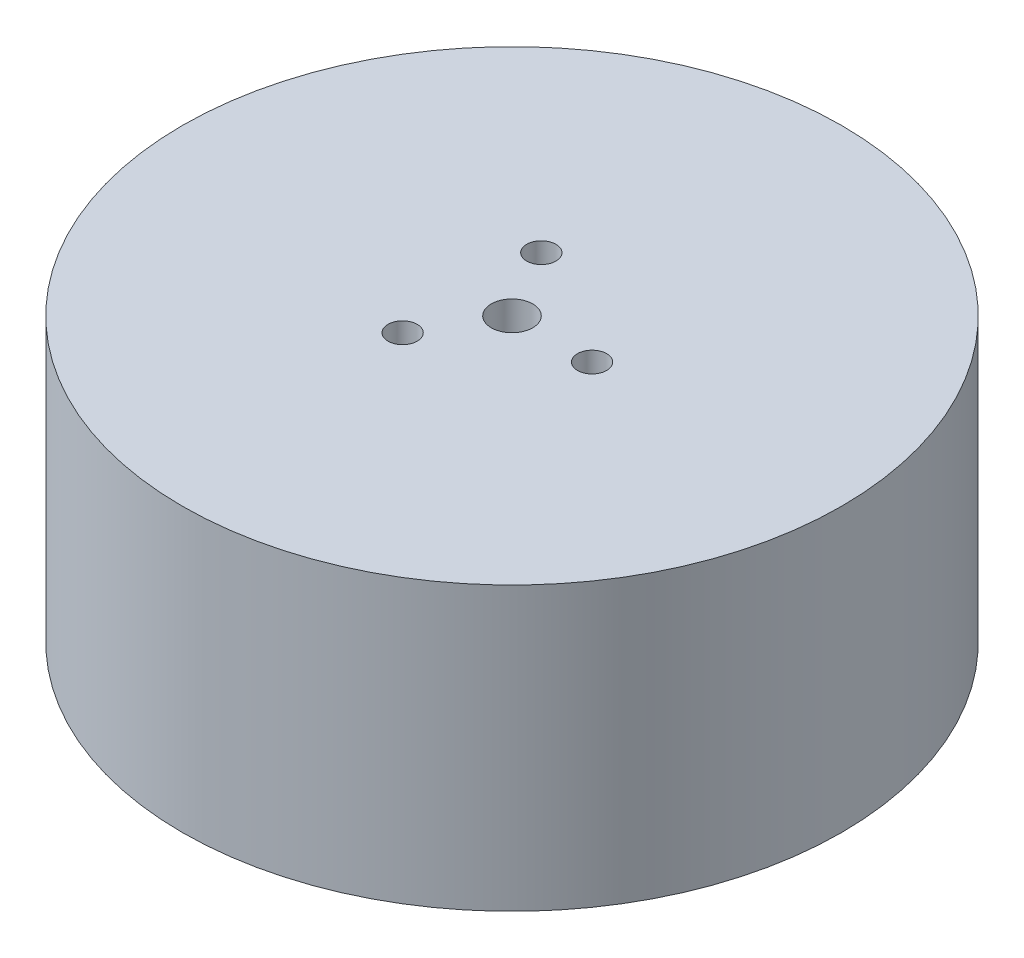
from build123d import *

# Parameters (mm, degrees)
SKETCH_1_R          = 35
EXTRUDE_1_DEPTH     = 30
SKETCH_2_R          = 23.2
CUT_EXTRUDE_1_DEPTH = 26
CUT_EXTRUDE_2_REACH = 32
SKETCH_3_R          = 2.2
SKETCH_3_R_2        = 1.55


with BuildPart() as part:
    # 草图1 → 凸台-拉伸1 (new body)
    with BuildSketch(Plane(origin=(0, 0, 0), x_dir=(1, 0, 0), z_dir=(0, 1, 0))):
        Circle(SKETCH_1_R)
    extrude(amount=EXTRUDE_1_DEPTH)

    # 草图2 → 切除-拉伸1 (cut)
    with BuildSketch(Plane.XZ):
        Circle(SKETCH_2_R)
    extrude(amount=-CUT_EXTRUDE_1_DEPTH, mode=Mode.SUBTRACT)

    # 草图3 → 切除-拉伸2 (cut, up to next)
    with BuildSketch(Plane(origin=(0, 30, 0), x_dir=(1, 0, 0), z_dir=(0, 1, 0)), mode=Mode.PRIVATE) as cut_extrude_2_sk1:
        Circle(SKETCH_3_R)
    cut_extrude_2_tool1 = extrude(cut_extrude_2_sk1.sketch, amount=-CUT_EXTRUDE_2_REACH, mode=Mode.PRIVATE) & part.part
    add(cut_extrude_2_tool1.solids().sort_by_distance((0, 30, 0))[0], mode=Mode.SUBTRACT)
    # 草图3 → 切除-拉伸2 (cut, up to next)
    with BuildSketch(Plane(origin=(0, 30, 0), x_dir=(1, 0, 0), z_dir=(0, 1, 0)), mode=Mode.PRIVATE) as cut_extrude_2_sk2:
        with Locations((8.5, 0)):
            Circle(SKETCH_3_R_2)
    cut_extrude_2_tool2 = extrude(cut_extrude_2_sk2.sketch, amount=-CUT_EXTRUDE_2_REACH, mode=Mode.PRIVATE) & part.part
    add(cut_extrude_2_tool2.solids().sort_by_distance((8.5, 30, 0))[0], mode=Mode.SUBTRACT)
    # 草图3 → 切除-拉伸2 (cut, up to next)
    with BuildSketch(Plane(origin=(0, 30, 0), x_dir=(1, 0, 0), z_dir=(0, 1, 0)), mode=Mode.PRIVATE) as cut_extrude_2_sk3:
        with Locations((-4.25, -7.361215932)):
            Circle(SKETCH_3_R_2)
    cut_extrude_2_tool3 = extrude(cut_extrude_2_sk3.sketch, amount=-CUT_EXTRUDE_2_REACH, mode=Mode.PRIVATE) & part.part
    add(cut_extrude_2_tool3.solids().sort_by_distance((-4.25, 30, 7.361216))[0], mode=Mode.SUBTRACT)
    # 草图3 → 切除-拉伸2 (cut, up to next)
    with BuildSketch(Plane(origin=(0, 30, 0), x_dir=(1, 0, 0), z_dir=(0, 1, 0)), mode=Mode.PRIVATE) as cut_extrude_2_sk4:
        with Locations((-4.25, 7.361215932)):
            Circle(SKETCH_3_R_2)
    cut_extrude_2_tool4 = extrude(cut_extrude_2_sk4.sketch, amount=-CUT_EXTRUDE_2_REACH, mode=Mode.PRIVATE) & part.part
    add(cut_extrude_2_tool4.solids().sort_by_distance((-4.25, 30, -7.361216))[0], mode=Mode.SUBTRACT)


solid = part.part
